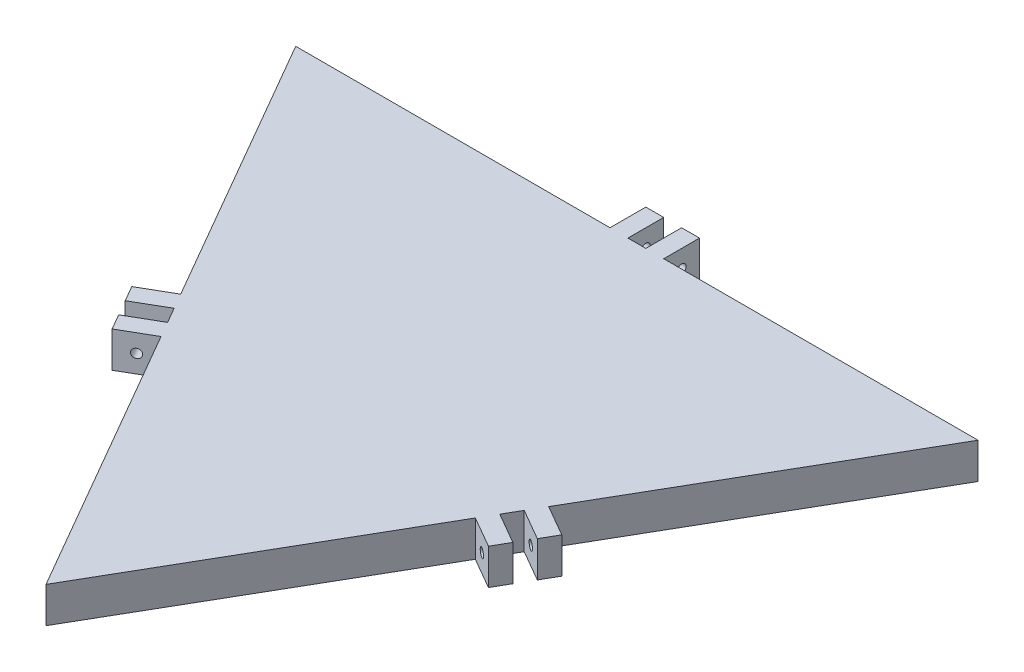
from build123d import *

# Parameters (mm, degrees)
BOSS_EXTRUDE1_DEPTH = 20
SKETCH3_W           = 10
SKETCH3_H           = 20
BOSS_EXTRUDE2_DEPTH = 20
SKETCH4_R           = 2.5
CUT_EXTRUDE1_DEPTH  = 30


with BuildPart() as part:
    # Sketch2 → Boss-Extrude1 (new body)
    with BuildSketch(Plane(origin=(0, 0, 0), x_dir=(1, 0, 0), z_dir=(0, 1, 0))):
        Polygon((-190.55, 110.014093794), (190.55, 110.014093794), (0, -220.028187588), align=None)
    extrude(amount=BOSS_EXTRUDE1_DEPTH)

    # Sketch3 → Boss-Extrude2 (add)
    with BuildSketch(Plane(origin=(95.275, 0, 55.007046897), x_dir=(0.5, 0, -0.866025404), z_dir=(0.866025404, 0, 0.5))):
        with Locations((-10, 10)):
            Rectangle(SKETCH3_W, SKETCH3_H)
        with Locations((10, 10)):
            Rectangle(SKETCH3_W, SKETCH3_H)
    boss_extrude2 = extrude(amount=BOSS_EXTRUDE2_DEPTH)

    # Sketch4 → Cut-Extrude1 (cut)
    with BuildSketch(Plane(origin=(-7.5, 0, 12.990381057), x_dir=(0.866025404, 0, 0.5), z_dir=(-0.5, 0, 0.866025404))):
        with Locations((120.014093794, 10)):
            Circle(SKETCH4_R)
    cut_extrude1 = extrude(amount=-CUT_EXTRUDE1_DEPTH, mode=Mode.SUBTRACT)

    # Mirror1: Boss-Extrude2, Cut-Extrude1 across plane
    add(boss_extrude2.mirror(Plane(origin=(0, 0, 0), x_dir=(-0.866025404, 0, 0.5), z_dir=(0.5, 0, 0.866025404))))
    add(cut_extrude1.mirror(Plane(origin=(0, 0, 0), x_dir=(-0.866025404, 0, 0.5), z_dir=(0.5, 0, 0.866025404))), mode=Mode.SUBTRACT)

    # Mirror1 at the second plane: Boss-Extrude2, Cut-Extrude1 across plane
    add(boss_extrude2.mirror(Plane(origin=(0, 0, 0), x_dir=(0, 0, 1), z_dir=(1, 0, 0))))
    add(cut_extrude1.mirror(Plane(origin=(0, 0, 0), x_dir=(0, 0, 1), z_dir=(1, 0, 0))), mode=Mode.SUBTRACT)


solid = part.part
